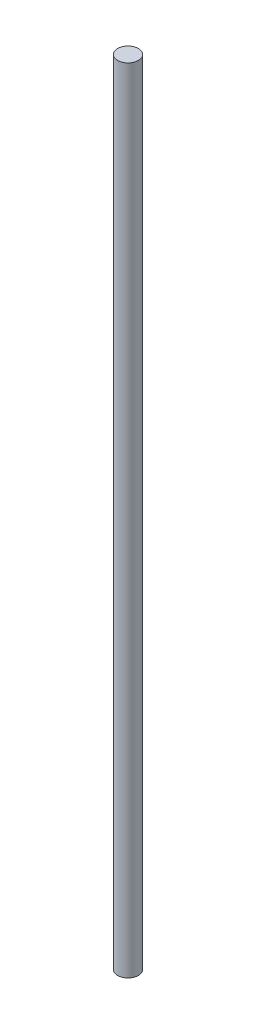
from build123d import *

# Parameters (mm, degrees)
ESQUISSE1_R = 4


with BuildPart() as part:
    # Balayage1: sweep along a path in Esquisse2
    with BuildLine(Plane.XY) as balayage1_path:
        Line((0, 0), (0, 306))
    # Esquisse1 → Balayage1 (sweep)
    with BuildSketch(Plane(origin=(0, 0, 0), x_dir=(1, 0, 0), z_dir=(0, 1, 0))):
        Circle(ESQUISSE1_R)
    sweep(path=balayage1_path.line)


solid = part.part
